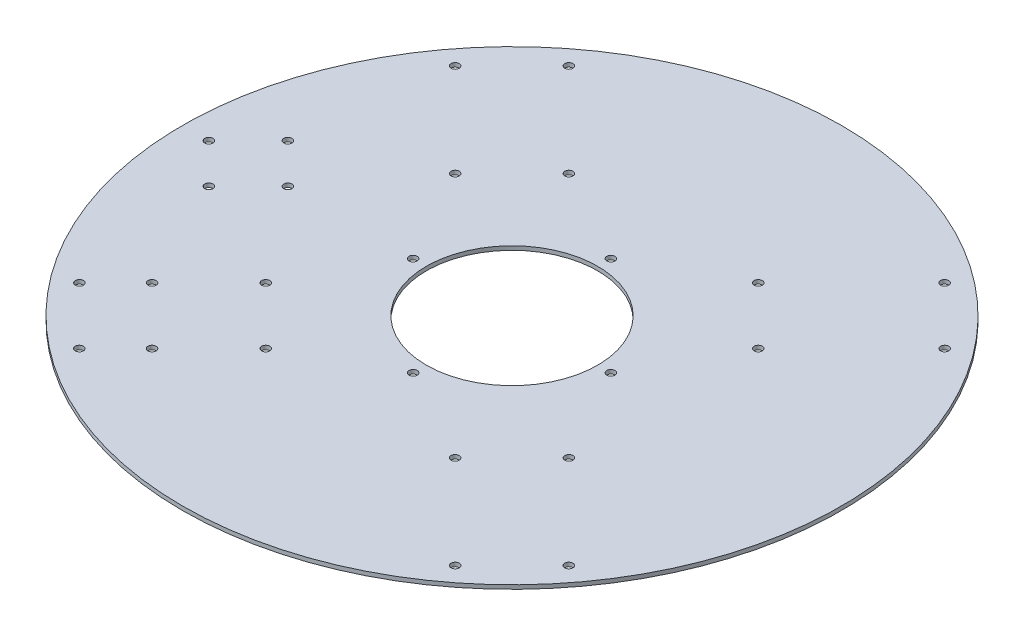
from build123d import *

# Parameters (mm, degrees)
SKETCH1_R           = 125
SKETCH1_R_2         = 1.55
SKETCH1_R_3         = 32.5
BOSS_EXTRUDE1_DEPTH = 1.5
SKETCH2_R           = 1.549999995
SKETCH2_R_2         = 1.550000001
SKETCH2_R_3         = 1.550000005
SKETCH2_R_4         = 1.55
CUT_EXTRUDE1_DEPTH  = 1.5
SKETCH3_R           = 1.55
CUT_EXTRUDE2_DEPTH  = 1.5


with BuildPart() as part:
    # Sketch1 → Boss-Extrude1 (new body)
    with BuildSketch(Plane(origin=(0, 0, 0), x_dir=(1, 0, 0), z_dir=(0, 1, 0))):
        Circle(SKETCH1_R)
        with Locations((0, -37.5)):
            Circle(SKETCH1_R_2, mode=Mode.SUBTRACT)
        with Locations((0, 37.5)):
            Circle(SKETCH1_R_2, mode=Mode.SUBTRACT)
        with Locations((37.5, 0)):
            Circle(SKETCH1_R_2, mode=Mode.SUBTRACT)
        with Locations((-37.5, 0)):
            Circle(SKETCH1_R_2, mode=Mode.SUBTRACT)
        Circle(SKETCH1_R_3, mode=Mode.SUBTRACT)
    extrude(amount=BOSS_EXTRUDE1_DEPTH)

    # Sketch2 → Cut-Extrude1 (cut)
    with BuildSketch(Plane(origin=(0, 1.5, 0), x_dir=(1, 0, 0), z_dir=(0, 1, 0))):
        with Locations((-71.269065604, 92.835829434)):
            Circle(SKETCH2_R)
        with Locations((-35.913726545, 57.480490375)):
            Circle(SKETCH2_R)
        with Locations((-92.835822431, 71.269072608)):
            Circle(SKETCH2_R)
        with Locations((-57.480483371, 35.913733548)):
            Circle(SKETCH2_R)
        with Locations((71.269072585, 92.835822411)):
            Circle(SKETCH2_R_2)
        with Locations((92.835829411, 71.269065585)):
            Circle(SKETCH2_R_2)
        with Locations((35.913733525, 57.480483351)):
            Circle(SKETCH2_R_2)
        with Locations((57.480490352, 35.913726525)):
            Circle(SKETCH2_R_2)
        with Locations((92.835822388, -71.269072605)):
            Circle(SKETCH2_R_3)
        with Locations((71.269065562, -92.835829431)):
            Circle(SKETCH2_R_3)
        with Locations((57.480483329, -35.913733545)):
            Circle(SKETCH2_R_3)
        with Locations((35.913726502, -57.480490371)):
            Circle(SKETCH2_R_3)
        with Locations((-71.269072628, -92.835822408)):
            Circle(SKETCH2_R_2)
        with Locations((-92.835829454, -71.269065582)):
            Circle(SKETCH2_R_2)
        with Locations((-35.913733568, -57.480483348)):
            Circle(SKETCH2_R_2)
        with Locations((-57.480490394, -35.913726522)):
            Circle(SKETCH2_R_2)
        with Locations((-57.480490394, -79.047240175)):
            Circle(SKETCH2_R_4)
        with Locations((-79.047247221, -57.480483348)):
            Circle(SKETCH2_R_4)
    extrude(amount=-CUT_EXTRUDE1_DEPTH, mode=Mode.SUBTRACT)

    # Sketch3 → Cut-Extrude2 (cut)
    with BuildSketch(Plane(origin=(0, 1.5, 0), x_dir=(1, 0, 0), z_dir=(0, 1, 0))):
        with Locations((-100, 15)):
            Circle(SKETCH3_R)
        with Locations((-100, -15)):
            Circle(SKETCH3_R)
        with Locations((-85, 0)):
            Circle(SKETCH3_R)
        with Locations((-115, 0)):
            Circle(SKETCH3_R)
    extrude(amount=-CUT_EXTRUDE2_DEPTH, mode=Mode.SUBTRACT)


solid = part.part
